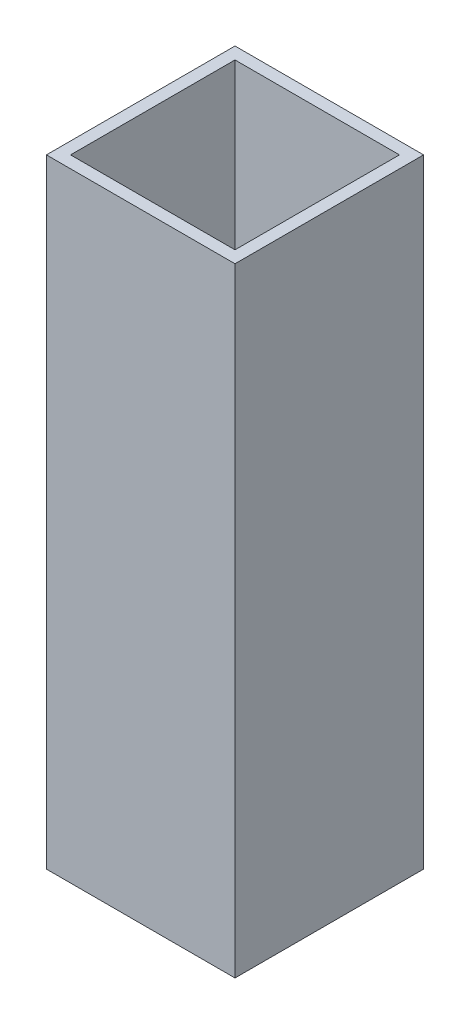
from build123d import *

# Parameters (mm, degrees)
SKETCH1_W           = 12.5
SKETCH1_H           = 12.5
BOSS_EXTRUDE1_DEPTH = 41
SHELL1_T            = -0.8


with BuildPart() as part:
    # Sketch1 → Boss-Extrude1 (new body)
    with BuildSketch(Plane(origin=(0, 0, 0), x_dir=(1, 0, 0), z_dir=(0, 1, 0))):
        with Locations((1.463963964, -1.60472973)):
            Rectangle(SKETCH1_W, SKETCH1_H)
    extrude(amount=BOSS_EXTRUDE1_DEPTH)

    # Shell1
    shell1_openings = [part.faces().sort_by_distance(p)[0] for p in [
        (1.463963964, 41, 1.60472973),
    ]]
    offset(amount=SHELL1_T, openings=shell1_openings, kind=Kind.INTERSECTION)


solid = part.part
